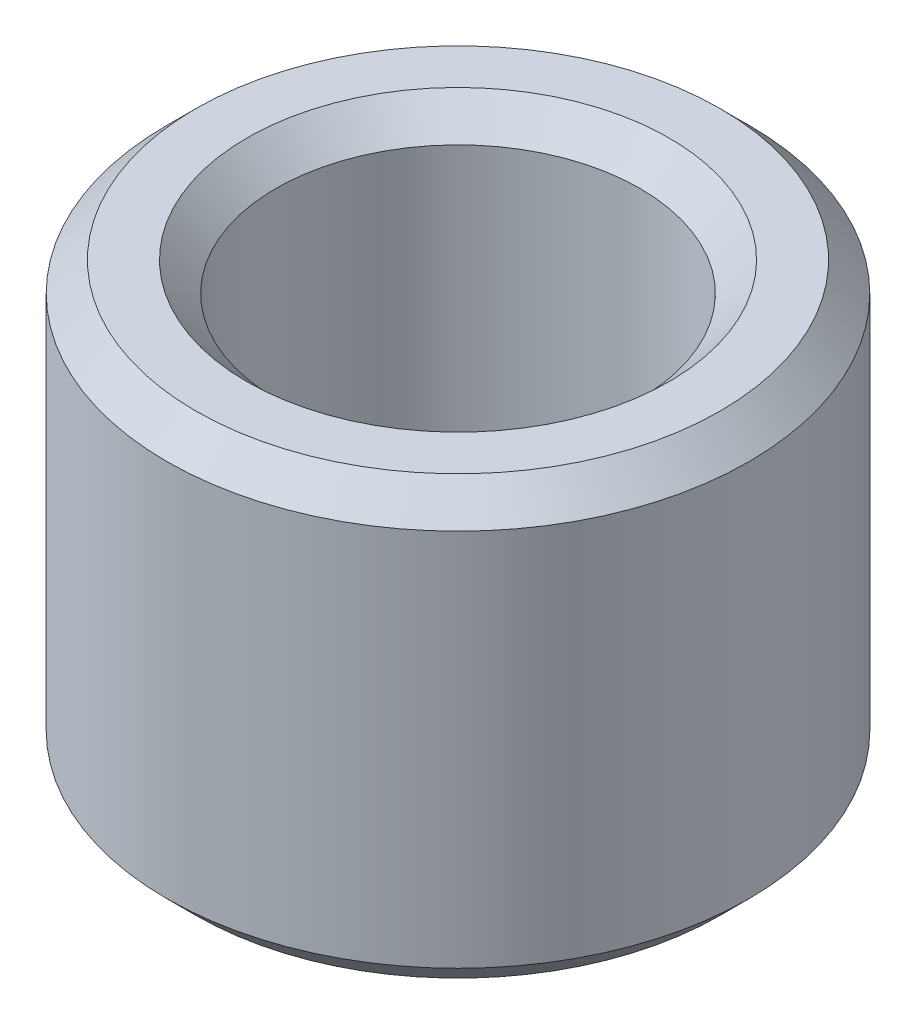
from build123d import *

# Parameters (mm, degrees)
SKETCH1_R           = 2
SKETCH1_R_2         = 1.25
BOSS_EXTRUDE1_DEPTH = 3
CHAMFER1_SIZE       = 0.2


with BuildPart() as part:
    # Sketch1 → Boss-Extrude1 (new body)
    with BuildSketch(Plane(origin=(0, 0, 0), x_dir=(1, 0, 0), z_dir=(0, 1, 0))):
        Circle(SKETCH1_R)
        Circle(SKETCH1_R_2, mode=Mode.SUBTRACT)
    extrude(amount=BOSS_EXTRUDE1_DEPTH)

    # Chamfer1
    chamfer1_edges = [part.edges().sort_by_distance(p)[0] for p in [
        (-2, 0, 0),
        (-2, 3, 0),
        (-1.25, 0, 0),
        (-1.25, 3, 0),
    ]]
    chamfer(chamfer1_edges, length=CHAMFER1_SIZE)


solid = part.part
